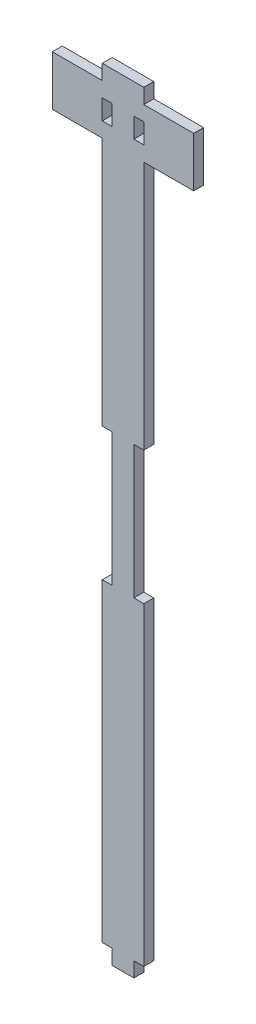
from build123d import *

# Parameters (mm, degrees)
SKETCH2_W           = 3
SKETCH2_H           = 6
BOSS_EXTRUDE1_DEPTH = 3


with BuildPart() as part:
    # Sketch2 → Boss-Extrude1 (new body)
    with BuildSketch(Plane.XY):
        Polygon((3.378431315, -114.5), (3.378431315, -119), (-3.121568685, -119), (-3.121568685, -114.5), (-6.121568685, -114.5), (-6.121568685, -20), (-3.121568685, -20), (-3.121568685, 20), (-6.121568685, 20), (-6.121568685, 95), (-21.121568685, 95), (-21.121568685, 110), (-6.121568685, 110), (-6.121568685, 114.5), (6.378431315, 114.5), (6.378431315, 110), (21.378431315, 110), (21.378431315, 95), (6.378431315, 95), (6.378431315, 20), (3.378431315, 20), (3.378431315, -20), (6.378431315, -20), (6.378431315, -114.5), align=None)
        with Locations((4.878431315, 102.5)):
            Rectangle(SKETCH2_W, SKETCH2_H, mode=Mode.SUBTRACT)
        with Locations((-4.621568685, 102.5)):
            Rectangle(SKETCH2_W, SKETCH2_H, mode=Mode.SUBTRACT)
    extrude(amount=BOSS_EXTRUDE1_DEPTH)


solid = part.part
